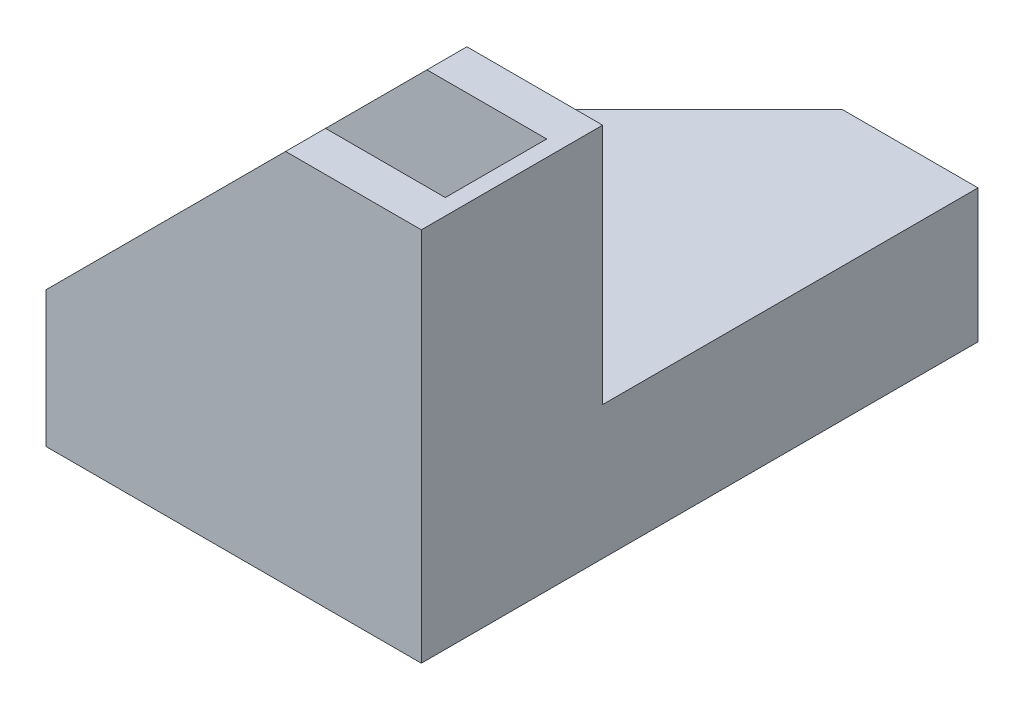
from build123d import *

# Parameters (mm, degrees)
BOSS_EXTRUDE1_DEPTH = 11.35
CUT_EXTRUDE1_DEPTH  = 6.35
BOSS_EXTRUDE2_DEPTH = 47
CUT_EXTRUDE2_DEPTH  = 47


with BuildPart() as part:
    # Sketch1 → Boss-Extrude1 (new body, symmetric)
    with BuildSketch(Plane.XY):
        Polygon((0, 0), (0, 47), (-17, 47), (-47, 17), (-47, 0), align=None)
    extrude(amount=BOSS_EXTRUDE1_DEPTH, both=True)

    # Sketch2 → Cut-Extrude1 (cut, symmetric)
    with BuildSketch(Plane.XY):
        Polygon((-47, 17), (-47, 2), (-2, 2), (-2, 47), (-17, 47), align=None)
    extrude(amount=CUT_EXTRUDE1_DEPTH, both=True, mode=Mode.SUBTRACT)

    # Sketch3 → Boss-Extrude2 (add)
    with BuildSketch(Plane(origin=(0, 0, -11.35), x_dir=(-1, 0, 0), z_dir=(0, 0, -1))):
        Polygon((0, 0), (0, 2), (0, 14.7), (0, 16.7), (47, 16.7), (47, 14.7), (2, 14.7), (2, 2), (47, 2), (47, 0), align=None)
    extrude(amount=BOSS_EXTRUDE2_DEPTH)

    # Sketch4 → Cut-Extrude2 (cut)
    with BuildSketch(Plane(origin=(0, 16.7, 0), x_dir=(1, 0, 0), z_dir=(0, 1, 0))):
        Polygon((-17, 58.35), (-47, 28.35), (-47, 58.35), align=None)
    extrude(amount=-CUT_EXTRUDE2_DEPTH, mode=Mode.SUBTRACT)


solid = part.part
